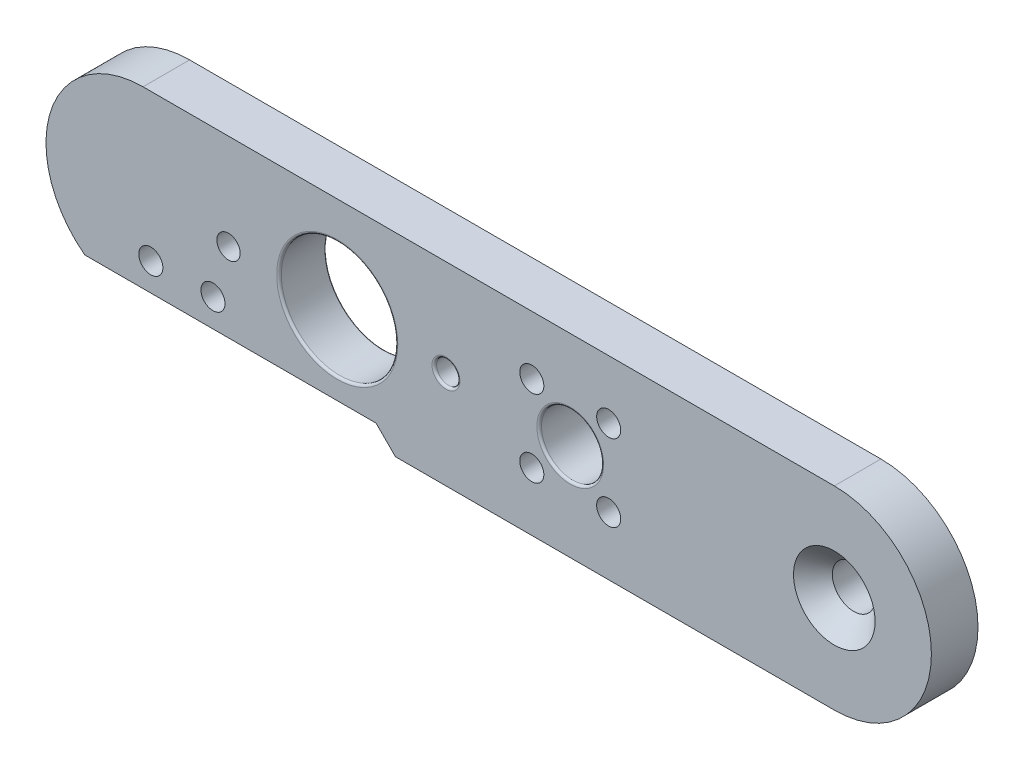
from build123d import *

# Parameters (mm, degrees)
BOSS_EXTRUDE1_DEPTH                             = 6
CUT_EXTRUDE2_START                              = -6
CUT_EXTRUDE2_DEPTH                              = 6
SKETCH4_3_R                                     = 4
SKETCH4_3_R_2                                   = 1.55
SKETCH4_3_R_3                                   = 7.5
CUT_EXTRUDE3_DEPTH                              = 6
F_3_0MM_DOWEL_HOLE1_D                           = 3
SKETCH8_R                                       = 1.55
CUT_EXTRUDE4_DEPTH                              = 3
SKETCH9_R                                       = 3
CUT_EXTRUDE5_DEPTH                              = 3
CSK_FOR_M5_FLAT_HEAD_MACHINE_SCREW2_D           = 5.5
CSK_FOR_M5_FLAT_HEAD_MACHINE_SCREW2_CSINK_D     = 10.5
CSK_FOR_M5_FLAT_HEAD_MACHINE_SCREW2_CSINK_ANGLE = 90
FILLET1_R                                       = 0.1
FILLET2_R                                       = 0.3


with BuildPart() as part:
    # Sketch2 → Boss-Extrude1 (new body)
    with BuildSketch(Plane.XY):
        with BuildLine():
            Line((-44.5, 12.5), (44.5, 12.5))
            ThreePointArc((44.5, 12.5), (57, 0), (44.5, -12.5))
            Line((44.5, -12.5), (-44.5, -12.5))
            ThreePointArc((-44.5, -12.5), (-57, 0), (-44.5, 12.5))
        make_face()
    extrude(amount=BOSS_EXTRUDE1_DEPTH)

    # Sketch4 → Cut-Extrude2 (cut)
    with BuildSketch(Plane.XY.offset(6).offset(CUT_EXTRUDE2_START)):
        with BuildLine():
            Line((-26.951366151, -10), (-52, -10))
            ThreePointArc((-52, -10), (-48.452847075, -11.858541226), (-44.5, -12.5))
            Line((-44.5, -12.5), (-12, -12.5))
            Line((-12, -12.5), (-14.5, -10))
            Line((-14.5, -10), (-26.951366151, -10))
        make_face()
    extrude(amount=CUT_EXTRUDE2_DEPTH, mode=Mode.SUBTRACT)

    # Sketch4_3 → Cut-Extrude3 (cut)
    with BuildSketch(Plane.XY.offset(6)):
        with Locations((10.5, 0)):
            Circle(SKETCH4_3_R)
        with Locations((5.550252532, 4.949747468)):
            Circle(SKETCH4_3_R_2)
        with Locations((-19.5, 0.176232127)):
            Circle(SKETCH4_3_R_3)
        with Locations((15.449747468, 4.949747468)):
            Circle(SKETCH4_3_R_2)
        with Locations((15.449747468, -4.949747468)):
            Circle(SKETCH4_3_R_2)
        with Locations((5.550252532, -4.949747468)):
            Circle(SKETCH4_3_R_2)
    extrude(amount=-CUT_EXTRUDE3_DEPTH, mode=Mode.SUBTRACT)

    # Ø3.0mm Dowel Hole1 (through all)
    with Locations(Plane.XY.offset(6)):
        with Locations((-5.500155789, 0.082828829), (-33.5, 0.176232127), (-19.5, 0.176232127)):
            Hole(F_3_0MM_DOWEL_HOLE1_D / 2)

    # Sketch8 → Cut-Extrude4 (cut)
    with BuildSketch(Plane.XY.offset(6)):
        with Locations((-43.5, -6.413742831)):
            Circle(SKETCH8_R)
        with Locations((-35.5, -6.413742831)):
            Circle(SKETCH8_R)
    extrude(amount=-CUT_EXTRUDE4_DEPTH, mode=Mode.SUBTRACT)

    # Sketch9 → Cut-Extrude5 (cut)
    with BuildSketch(Plane.XY.offset(3)):
        with Locations((-43.5, -6.413742831)):
            Circle(SKETCH9_R)
        with Locations((-35.5, -6.413742831)):
            Circle(SKETCH9_R)
    extrude(amount=-CUT_EXTRUDE5_DEPTH, mode=Mode.SUBTRACT)

    # CSK for M5 Flat Head Machine Screw2 (through all)
    with Locations(Plane.XY.offset(6)):
        with Locations((44.5, 0)):
            CounterSinkHole(CSK_FOR_M5_FLAT_HEAD_MACHINE_SCREW2_D / 2, CSK_FOR_M5_FLAT_HEAD_MACHINE_SCREW2_CSINK_D / 2, counter_sink_angle=CSK_FOR_M5_FLAT_HEAD_MACHINE_SCREW2_CSINK_ANGLE)

    # Fillet1
    fillet1_edges = [part.edges().sort_by_distance(p)[0] for p in [
        (-27, 0.176232127, 0),
        (6.5, 0, 0),
    ]]
    fillet(fillet1_edges, radius=FILLET1_R)

    # Fillet2
    fillet2_edges = [part.edges().sort_by_distance(p)[0] for p in [
        (6.5, 0, 6),
        (-4.000155789, 0.082828829, 6),
        (-4.000155789, 0.082828829, 0),
        (-27, 0.176232127, 6),
    ]]
    fillet(fillet2_edges, radius=FILLET2_R)


solid = part.part
